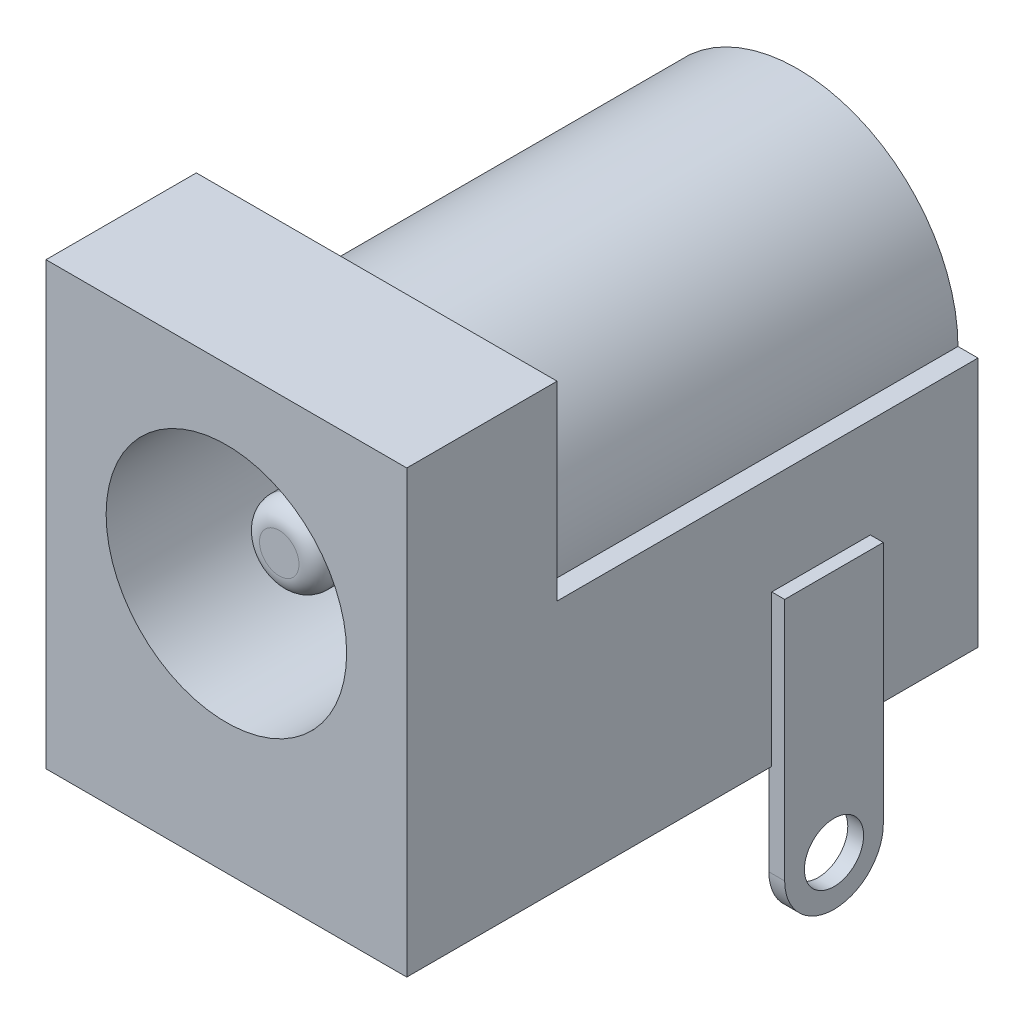
from build123d import *

# Parameters (mm, degrees)
SKETCH1_W           = 9.144
SKETCH1_H           = 11.176
BASE_EXTRUDE_DEPTH  = 3.81
BOSS_EXTRUDE1_DEPTH = 10.668
SKETCH3_R           = 3.048
CUT_EXTRUDE1_DEPTH  = 9.144
SKETCH4_R           = 1
EXTRUDE1_DEPTH      = 7.804
FILLET1_R           = 0.5
SKETCH5_R           = 0.75
EXTRUDE2_DEPTH      = 0.2
SKETCH6_R           = 0.75
EXTRUDE3_DEPTH      = 0.15
SKETCH7_R           = 0.75
EXTRUDE4_DEPTH      = 0.2


with BuildPart() as part:
    # Sketch1 → Base-Extrude (new body)
    with BuildSketch(Plane.XY):
        with Locations((0, 5.588)):
            Rectangle(SKETCH1_W, SKETCH1_H)
    extrude(amount=-BASE_EXTRUDE_DEPTH)

    # Sketch2 → Boss-Extrude1 (add)
    with BuildSketch(Plane(origin=(0, 0, -3.81), x_dir=(-1, 0, 0), z_dir=(0, 0, -1))):
        with BuildLine():
            Line((-4.572, 0), (-4.572, 6.35))
            Line((-4.572, 6.35), (-4.064, 6.35))
            ThreePointArc((-4.064, 6.35), (0, 10.414), (4.064, 6.35))
            Line((4.064, 6.35), (4.572, 6.35))
            Line((4.572, 6.35), (4.572, 0))
            Line((4.572, 0), (-4.572, 0))
        make_face()
    extrude(amount=BOSS_EXTRUDE1_DEPTH)

    # Sketch3 → Cut-Extrude1 (cut)
    with BuildSketch(Plane.XY):
        with Locations((0, 6.35)):
            Circle(SKETCH3_R)
    extrude(amount=-CUT_EXTRUDE1_DEPTH, mode=Mode.SUBTRACT)

    # Sketch4 → Extrude1 (add)
    with BuildSketch(Plane.XY.offset(-9.144)):
        with Locations((0, 6.35)):
            Circle(SKETCH4_R)
    extrude(amount=EXTRUDE1_DEPTH)

    # Fillet1
    fillet1_edges = [part.edges().sort_by_distance(p)[0] for p in [
        (-1, 6.35, -1.34),
    ]]
    fillet(fillet1_edges, radius=FILLET1_R)

    # Sketch5 → Extrude2 (add, symmetric)
    with BuildSketch(Plane(origin=(4.7, 0, 0), x_dir=(0, 0, -1), z_dir=(1, 0, 0))):
        with BuildLine():
            Line((11.75, 3.83), (11.75, -2.35))
            ThreePointArc((11.75, -2.35), (10.5, -3.6), (9.25, -2.35))
            Line((9.25, -2.35), (9.25, 3.83))
            Line((9.25, 3.83), (11.75, 3.83))
        make_face()
        with Locations((10.5, -2.35)):
            Circle(SKETCH5_R, mode=Mode.SUBTRACT)
    extrude(amount=EXTRUDE2_DEPTH, both=True)

    # Sketch6 → Extrude3 (add, symmetric)
    with BuildSketch(Plane(origin=(0, 0, -7.5), x_dir=(-1, 0, 0), z_dir=(0, 0, 1))):
        with BuildLine():
            Line((-1.1, 0), (-1.1, 2.5))
            ThreePointArc((-1.1, 2.5), (0, 3.6), (1.1, 2.5))
            Line((1.1, 2.5), (1.1, 0))
            Line((1.1, 0), (-1.1, 0))
        make_face()
        with Locations((0, 2.5)):
            Circle(SKETCH6_R, mode=Mode.SUBTRACT)
    extrude(amount=EXTRUDE3_DEPTH, both=True)

    # Sketch7 → Extrude4 (add, symmetric)
    with BuildSketch(Plane.XY.offset(-13.7)):
        with BuildLine():
            Line((1.425, 0), (1.425, -2.175))
            ThreePointArc((1.425, -2.175), (0, -3.6), (-1.425, -2.175))
            Line((-1.425, -2.175), (-1.425, 0))
            Line((-1.425, 0), (1.425, 0))
        make_face()
        with Locations((0, -2.175)):
            Circle(SKETCH7_R, mode=Mode.SUBTRACT)
    extrude(amount=EXTRUDE4_DEPTH, both=True)


solid = part.part
